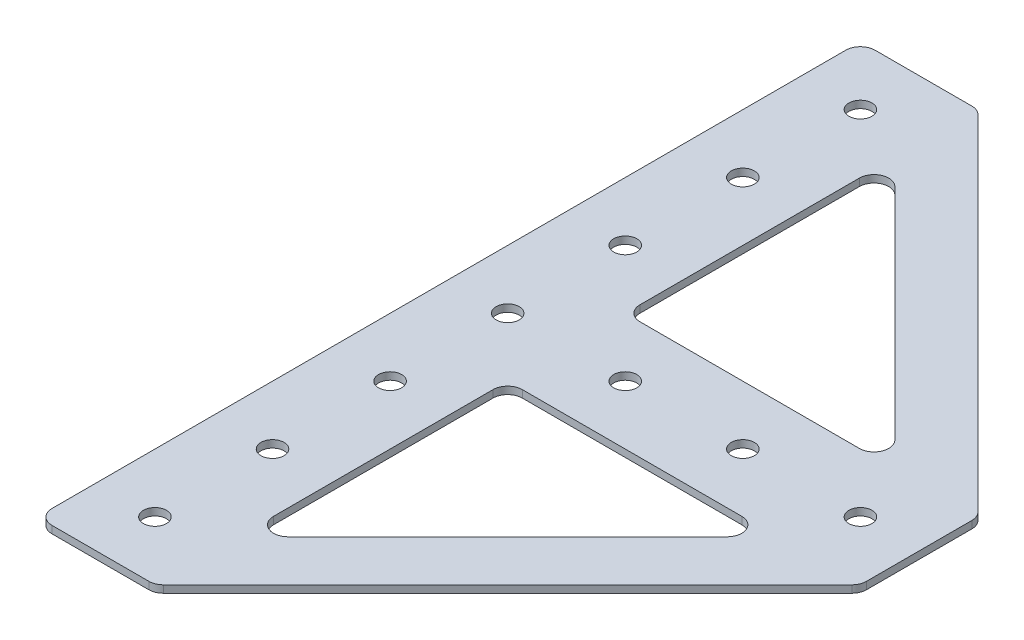
from build123d import *

# Parameters (mm, degrees)
BOSS_EXTRUDE1_DEPTH        = 1.5875
F_9_0_196_DIAMETER_HOLE1_D = 4.9784
LPATTERN1_COUNT            = 4
LPATTERN1_PITCH            = 25.4
LPATTERN1_COL_COUNT        = 4
LPATTERN1_COL_PITCH        = 25.4
LPATTERN2_COUNT            = 4
LPATTERN2_PITCH            = 25.4
FILLET1_R                  = 3.175


with BuildPart() as part:
    # Sketch1 → Boss-Extrude1 (new body)
    with BuildSketch(Plane(origin=(0, 0, 0), x_dir=(1, 0, 0), z_dir=(0, 1, 0))):
        Polygon((101.6, 101.6), (101.6, 76.2), (25.4, 0), (0, 0), (0, 177.8), (25.4, 177.8), align=None)
        Polygon((25.4, 17.960512242), (83.639487758, 76.2), (25.4, 76.2), align=None, mode=Mode.SUBTRACT)
        Polygon((83.639487758, 101.6), (25.4, 159.839487758), (25.4, 101.6), align=None, mode=Mode.SUBTRACT)
    extrude(amount=BOSS_EXTRUDE1_DEPTH)

    # #9 (0.196) Diameter Hole1 (through all)
    with Locations(Plane(origin=(12.7, 1.5875, -88.9), x_dir=(0, 0, 1), z_dir=(0, 1, 0))):
        with Locations((0, 0)):
            f_9_0_196_diameter_hole1 = Hole(F_9_0_196_DIAMETER_HOLE1_D / 2)

    # LPattern1: #9 (0.196) Diameter Hole1 ×4
    with Locations(*[(0, 0, -i * LPATTERN1_PITCH) for i in range(1, LPATTERN1_COUNT)]):
        add(f_9_0_196_diameter_hole1, mode=Mode.SUBTRACT)

    # LPattern1 col: #9 (0.196) Diameter Hole1 ×4
    with Locations(*[(i * LPATTERN1_COL_PITCH, 0, 0) for i in range(1, LPATTERN1_COL_COUNT)]):
        add(f_9_0_196_diameter_hole1, mode=Mode.SUBTRACT)

    # LPattern2: #9 (0.196) Diameter Hole1 ×4
    with Locations(*[(0, 0, i * LPATTERN2_PITCH) for i in range(1, LPATTERN2_COUNT)]):
        add(f_9_0_196_diameter_hole1, mode=Mode.SUBTRACT)

    # Fillet1
    fillet1_edges = [part.edges().sort_by_distance(p)[0] for p in [
        (101.6, 0.79375, -76.2),
        (25.4, 0.79375, 0),
        (0, 0.79375, 0),
        (0, 0.79375, -177.8),
        (25.4, 0.79375, -177.8),
        (101.6, 0.79375, -101.6),
        (25.4, 0.79375, -159.839487758),
        (25.4, 0.79375, -101.6),
        (83.639487758, 0.79375, -101.6),
        (83.639487758, 0.79375, -76.2),
        (25.4, 0.79375, -76.2),
        (25.4, 0.79375, -17.960512242),
    ]]
    fillet(fillet1_edges, radius=FILLET1_R)


solid = part.part
